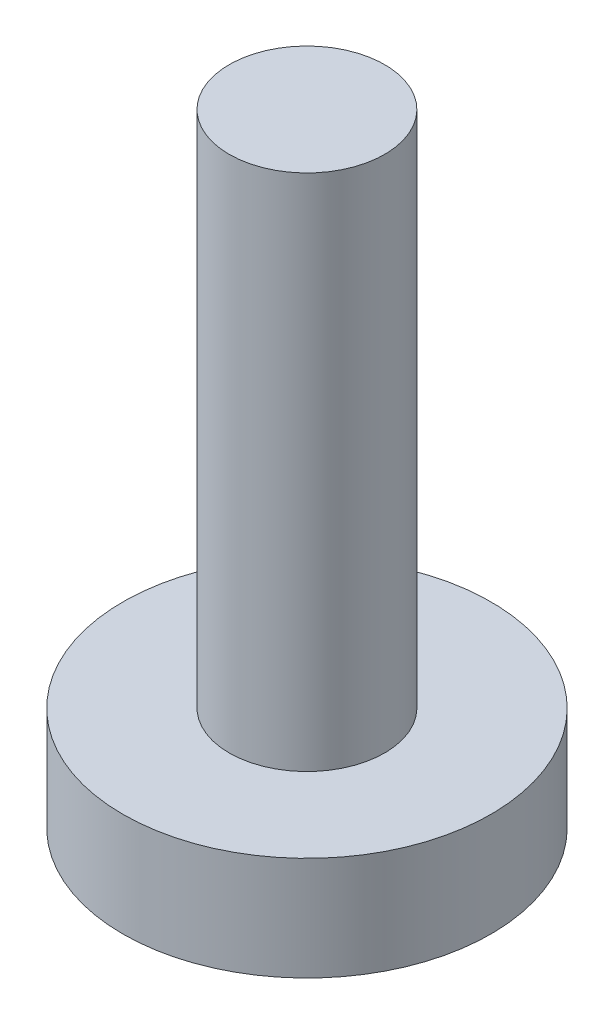
from build123d import *

# Parameters (mm, degrees)
SKETCH_1_R      = 3.55
EXTRUDE_1_DEPTH = 2
SKETCH_2_R      = 1.5
EXTRUDE_2_DEPTH = 10


with BuildPart() as part:
    # 草图1 → 凸台-拉伸1 (new body)
    with BuildSketch(Plane(origin=(0, 0, 0), x_dir=(1, 0, 0), z_dir=(0, 1, 0))):
        Circle(SKETCH_1_R)
    extrude(amount=EXTRUDE_1_DEPTH)

    # 草图2 → 凸台-拉伸2 (add)
    with BuildSketch(Plane(origin=(0, 2, 0), x_dir=(1, 0, 0), z_dir=(0, 1, 0))):
        Circle(SKETCH_2_R)
    extrude(amount=EXTRUDE_2_DEPTH)


solid = part.part
